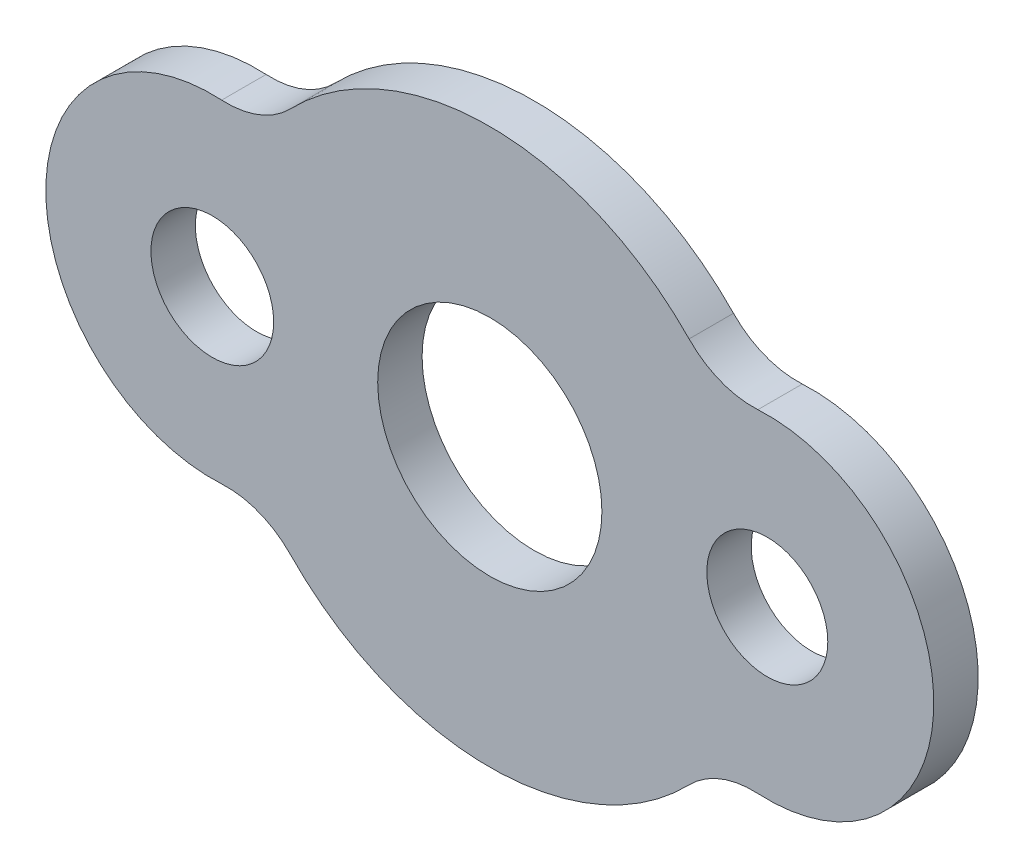
from build123d import *

# Parameters (mm, degrees)
SZKIC1_R                    = 27.245803964
SZKIC1_R_2                  = 27.636152319
SZKIC1_R_3                  = 50.5
DODANIE_WYCI_GNI_CIE1_DEPTH = 20


with BuildPart() as part:
    # Szkic1 → Dodanie-wyciągnięcie1 (new body)
    with BuildSketch(Plane.XY):
        with BuildLine():
            ThreePointArc((-120.760869565, 74.880102652), (-103.94901291, 77.556678408), (-89.772727273, 86.981937424))
            ThreePointArc((-89.772727273, 86.981937424), (0, 125), (89.772727273, 86.981937424))
            ThreePointArc((89.772727273, 86.981937424), (103.94901291, 77.556678408), (120.760869565, 74.880102652))
            ThreePointArc((120.760869565, 74.880102652), (200, 0), (120.760869565, -74.880102652))
            ThreePointArc((120.760869565, -74.880102652), (103.94901291, -77.556678408), (89.772727273, -86.981937424))
            ThreePointArc((89.772727273, -86.981937424), (0, -125), (-89.772727273, -86.981937424))
            ThreePointArc((-89.772727273, -86.981937424), (-103.94901291, -77.556678408), (-120.760869565, -74.880102652))
            ThreePointArc((-120.760869565, -74.880102652), (-200, 0), (-120.760869565, 74.880102652))
        make_face()
        with Locations((125, 0)):
            Circle(SZKIC1_R, mode=Mode.SUBTRACT)
        with Locations((-125, 0)):
            Circle(SZKIC1_R_2, mode=Mode.SUBTRACT)
        Circle(SZKIC1_R_3, mode=Mode.SUBTRACT)
    extrude(amount=DODANIE_WYCI_GNI_CIE1_DEPTH)


solid = part.part
